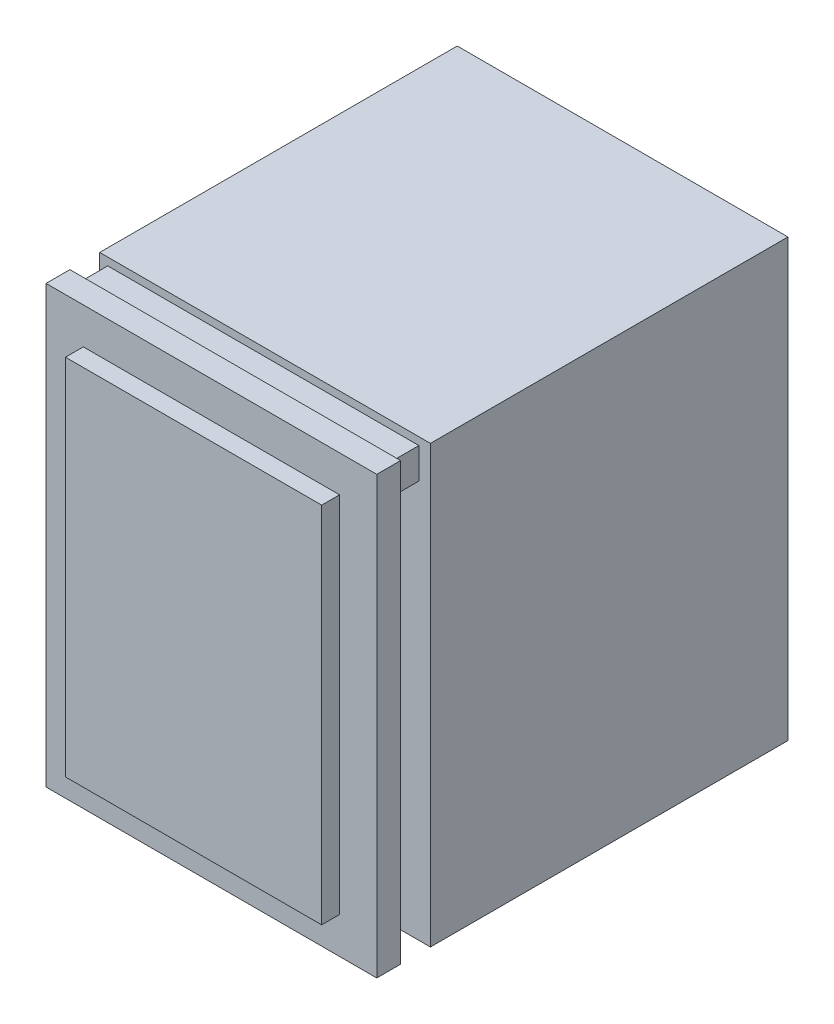
from build123d import *

# Parameters (mm, degrees)
SKETCH1_W           = 55.5
SKETCH1_H           = 73.2
BOSS_EXTRUDE1_DEPTH = 4
SKETCH2_W           = 52.220028237
SKETCH2_H           = 5.163547568
BOSS_EXTRUDE2_DEPTH = 5
SKETCH3_W           = 43
SKETCH3_H           = 61
BOSS_EXTRUDE3_DEPTH = 3
SKETCH4_W           = 55.5
SKETCH4_H           = 73.2
BOSS_EXTRUDE4_DEPTH = 60


with BuildPart() as part:
    # Sketch1 → Boss-Extrude1 (new body)
    with BuildSketch(Plane.XY):
        Rectangle(SKETCH1_W, SKETCH1_H)
    extrude(amount=BOSS_EXTRUDE1_DEPTH)

    # Sketch2 → Boss-Extrude2 (add)
    with BuildSketch(Plane(origin=(0, 0, 0), x_dir=(-1, 0, 0), z_dir=(0, 0, -1))):
        with Locations((0.292276277, 32.734943074)):
            Rectangle(SKETCH2_W, SKETCH2_H)
    extrude(amount=BOSS_EXTRUDE2_DEPTH)

    # Sketch3 → Boss-Extrude3 (add)
    with BuildSketch(Plane.XY.offset(4)):
        Rectangle(SKETCH3_W, SKETCH3_H)
    extrude(amount=BOSS_EXTRUDE3_DEPTH)

    # Sketch4 → Boss-Extrude4 (add)
    with BuildSketch(Plane(origin=(0, 0, -5), x_dir=(-1, 0, 0), z_dir=(0, 0, -1))):
        Rectangle(SKETCH4_W, SKETCH4_H)
    extrude(amount=BOSS_EXTRUDE4_DEPTH)


solid = part.part
